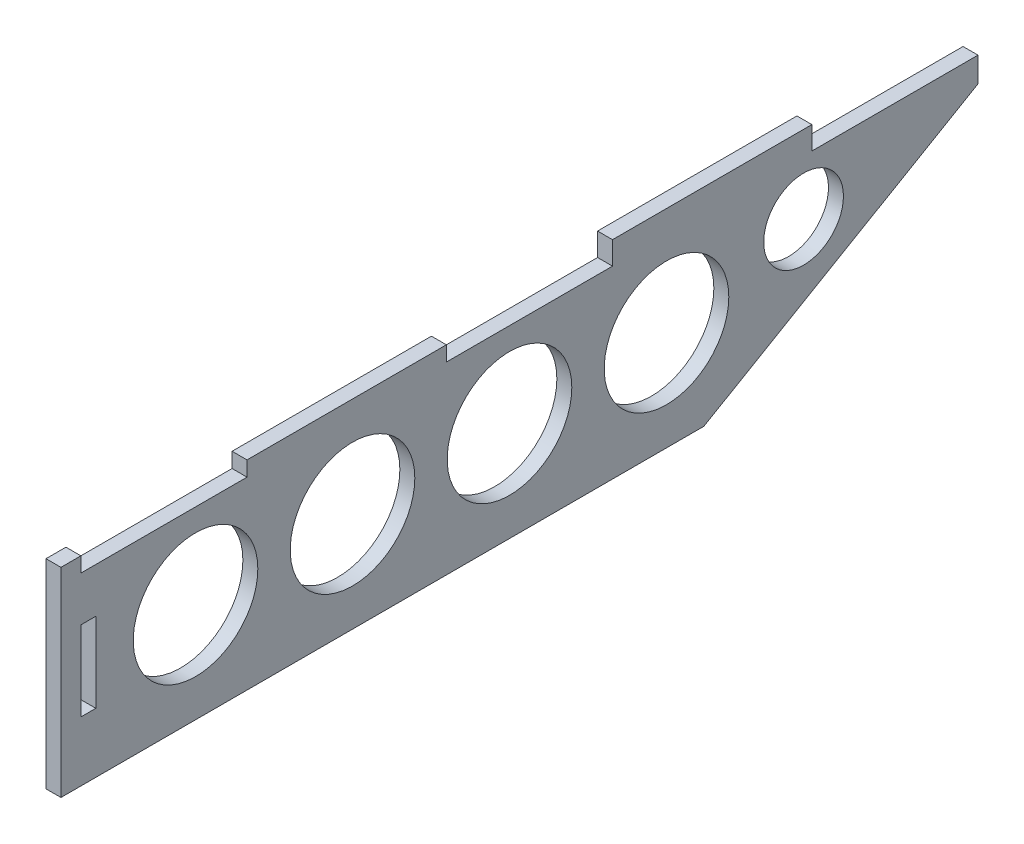
from build123d import *

# Parameters (mm, degrees)
SKETCH1_W           = 3
SKETCH1_H           = 16
SKETCH1_R           = 12.5
SKETCH1_R_2         = 8
BOSS_EXTRUDE1_DEPTH = 3
SKETCH2_W           = 40
SKETCH2_H           = 1.6
BOSS_EXTRUDE2_DEPTH = 3


with BuildPart() as part:
    # Sketch1 → Boss-Extrude1 (new body)
    with BuildSketch(Plane(origin=(0, 0, 0), x_dir=(0, 0, -1), z_dir=(1, 0, 0))):
        Polygon((125, -40), (180, -8), (180, -3), (146.666666667, -3), (146.666666667, 0), (106.666666667, 0), (106.666666667, -3), (73.333333333, -3), (73.333333333, 0), (33.333333333, 0), (33.333333333, -3), (0, -3), (0, 0), (-4, 0), (-4, -40), (0, -40), align=None)
        with Locations((1.5, -20)):
            Rectangle(SKETCH1_W, SKETCH1_H, mode=Mode.SUBTRACT)
        with Locations((23, -20)):
            Circle(SKETCH1_R, mode=Mode.SUBTRACT)
        with Locations((54.5, -20)):
            Circle(SKETCH1_R, mode=Mode.SUBTRACT)
        with Locations((86, -20)):
            Circle(SKETCH1_R, mode=Mode.SUBTRACT)
        with Locations((117.5, -20)):
            Circle(SKETCH1_R, mode=Mode.SUBTRACT)
        with Locations((145, -14)):
            Circle(SKETCH1_R_2, mode=Mode.SUBTRACT)
    extrude(amount=BOSS_EXTRUDE1_DEPTH)

    # Sketch2 → Boss-Extrude2 (add)
    with BuildSketch(Plane(origin=(3, 0, 0), x_dir=(0, 0, -1), z_dir=(1, 0, 0))):
        with Locations((126.666666667, 0.8)):
            Rectangle(SKETCH2_W, SKETCH2_H)
    extrude(amount=-BOSS_EXTRUDE2_DEPTH)


solid = part.part
